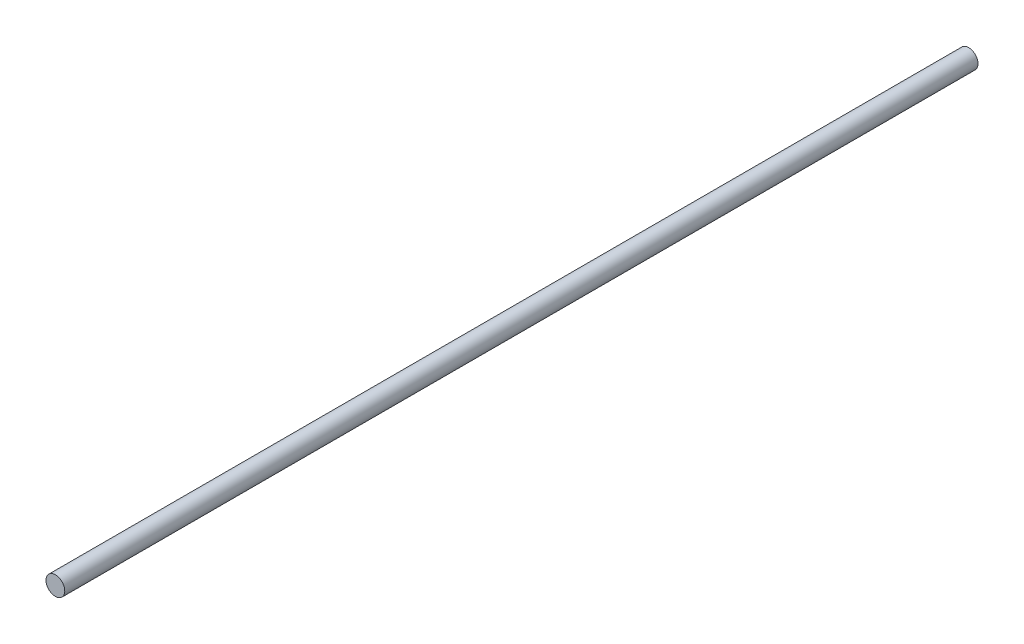
from build123d import *

# Parameters (mm, degrees)
SKETCH2_W = 389.2
SKETCH2_H = 4


with BuildPart() as part:
    # Sketch2 → Revolve1 (revolve)
    with BuildSketch(Plane(origin=(0, 0, 0), x_dir=(0, 0, -1), z_dir=(1, 0, 0))):
        with Locations((194.6, 2)):
            Rectangle(SKETCH2_W, SKETCH2_H)
    revolve(axis=Axis((0, 0, 0), (0, 0, 1)))


solid = part.part
